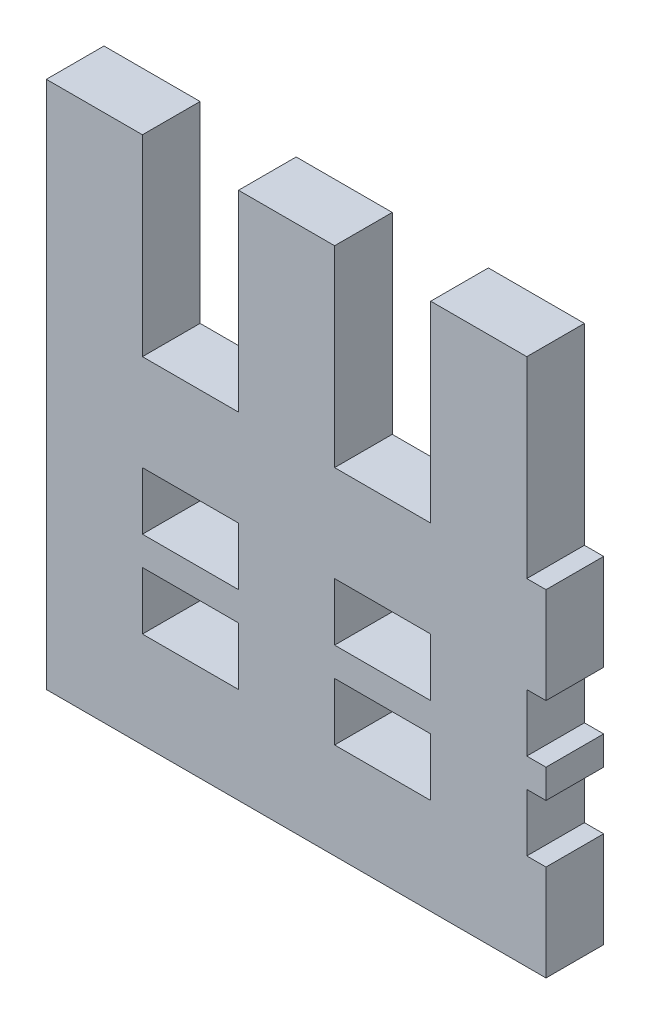
from build123d import *

# Parameters (mm, degrees)
ESQUISSE1_W        = 5
ESQUISSE1_H        = 3
BOSS_EXTRU_1_DEPTH = 3


with BuildPart() as part:
    # Esquisse1 → Boss.-Extru.1 (new body)
    with BuildSketch(Plane.XY):
        Polygon((-40.414818772, 48.638632865), (-40.414818772, 38.638632865), (-45.414818772, 38.638632865), (-45.414818772, 48.638632865), (-50.414818772, 48.638632865), (-50.414818772, 21.138632865), (-24.414818772, 21.138632865), (-24.414818772, 26.138632865), (-25.414818772, 26.138632865), (-25.414818772, 29.138632865), (-24.414818772, 29.138632865), (-24.414818772, 30.638632865), (-25.414818772, 30.638632865), (-25.414818772, 33.638632865), (-24.414818772, 33.638632865), (-24.414818772, 38.638632865), (-25.414818772, 38.638632865), (-25.414818772, 48.638632865), (-30.414818772, 48.638632865), (-30.414818772, 38.638632865), (-35.414818772, 38.638632865), (-35.414818772, 48.638632865), align=None)
        with Locations((-32.914818772, 27.638632865)):
            Rectangle(ESQUISSE1_W, ESQUISSE1_H, mode=Mode.SUBTRACT)
        with Locations((-42.914818772, 27.638632865)):
            Rectangle(ESQUISSE1_W, ESQUISSE1_H, mode=Mode.SUBTRACT)
        with Locations((-32.914818772, 32.138632865)):
            Rectangle(ESQUISSE1_W, ESQUISSE1_H, mode=Mode.SUBTRACT)
        with Locations((-42.914818772, 32.138632865)):
            Rectangle(ESQUISSE1_W, ESQUISSE1_H, mode=Mode.SUBTRACT)
    extrude(amount=BOSS_EXTRU_1_DEPTH)


solid = part.part
